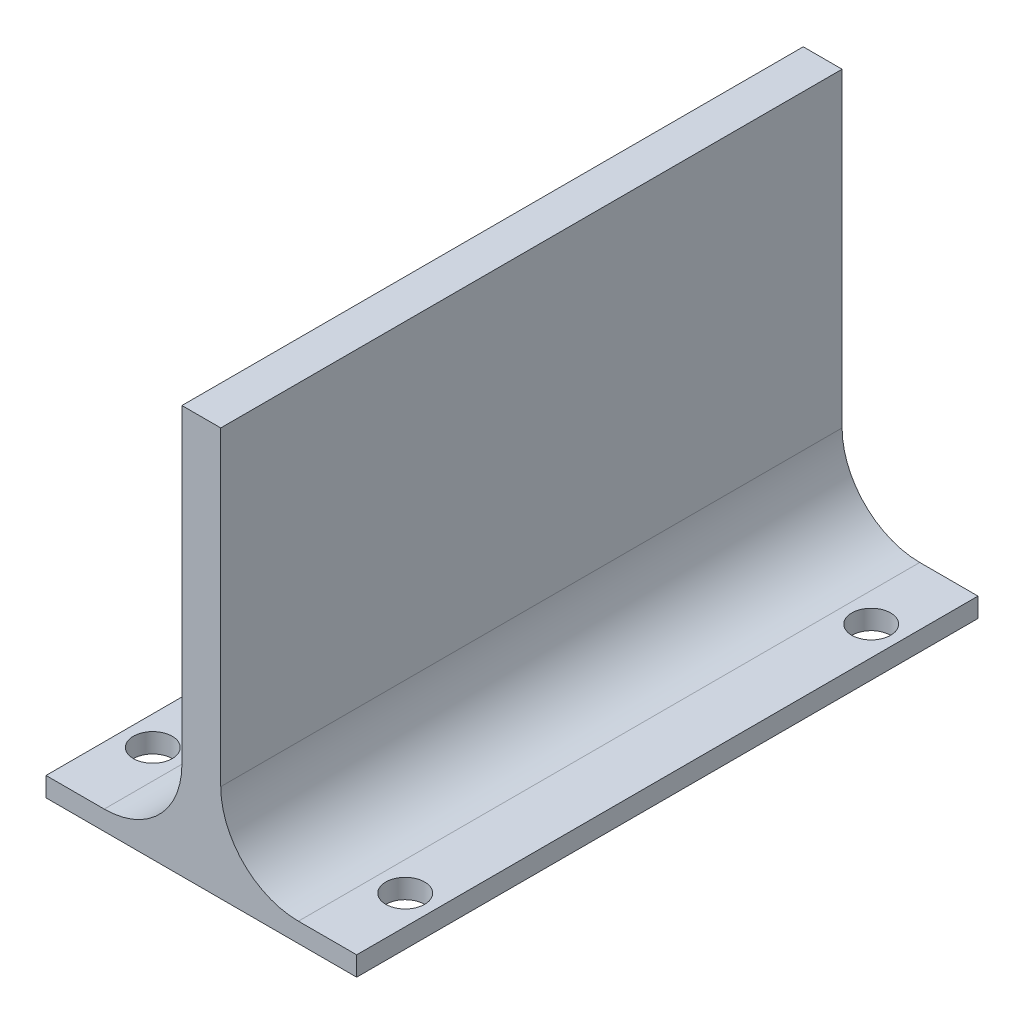
from build123d import *

# Parameters (mm, degrees)
SKETCH2_W           = 10
SKETCH2_H           = 100
SKETCH2_W_2         = 80
SKETCH2_H_2         = 5
BOSS_EXTRUDE2_DEPTH = 160
FILLET1_R           = 20
SKETCH3_R           = 5
CUT_EXTRUDE2_DEPTH  = 10


with BuildPart() as part:
    # Sketch2 → Boss-Extrude2 (new body)
    with BuildSketch(Plane.XY):
        with Locations((40, 50)):
            Rectangle(SKETCH2_W, SKETCH2_H)
        with Locations((40, -2.5)):
            Rectangle(SKETCH2_W_2, SKETCH2_H_2)
    extrude(amount=BOSS_EXTRUDE2_DEPTH)

    # Fillet1
    fillet1_edges = [part.edges().sort_by_distance(p)[0] for p in [
        (45, 0, 80),
        (35, 0, 80),
    ]]
    fillet(fillet1_edges, radius=FILLET1_R)

    # Sketch3 → Cut-Extrude2 (cut)
    with BuildSketch(Plane(origin=(0, 0, 0), x_dir=(1, 0, 0), z_dir=(0, 1, 0))):
        with Locations((72.5, -20)):
            Circle(SKETCH3_R)
        with Locations((72.5, -140)):
            Circle(SKETCH3_R)
        with Locations((7.5, -140)):
            Circle(SKETCH3_R)
        with Locations((7.5, -20)):
            Circle(SKETCH3_R)
    extrude(amount=-CUT_EXTRUDE2_DEPTH, mode=Mode.SUBTRACT)


solid = part.part
